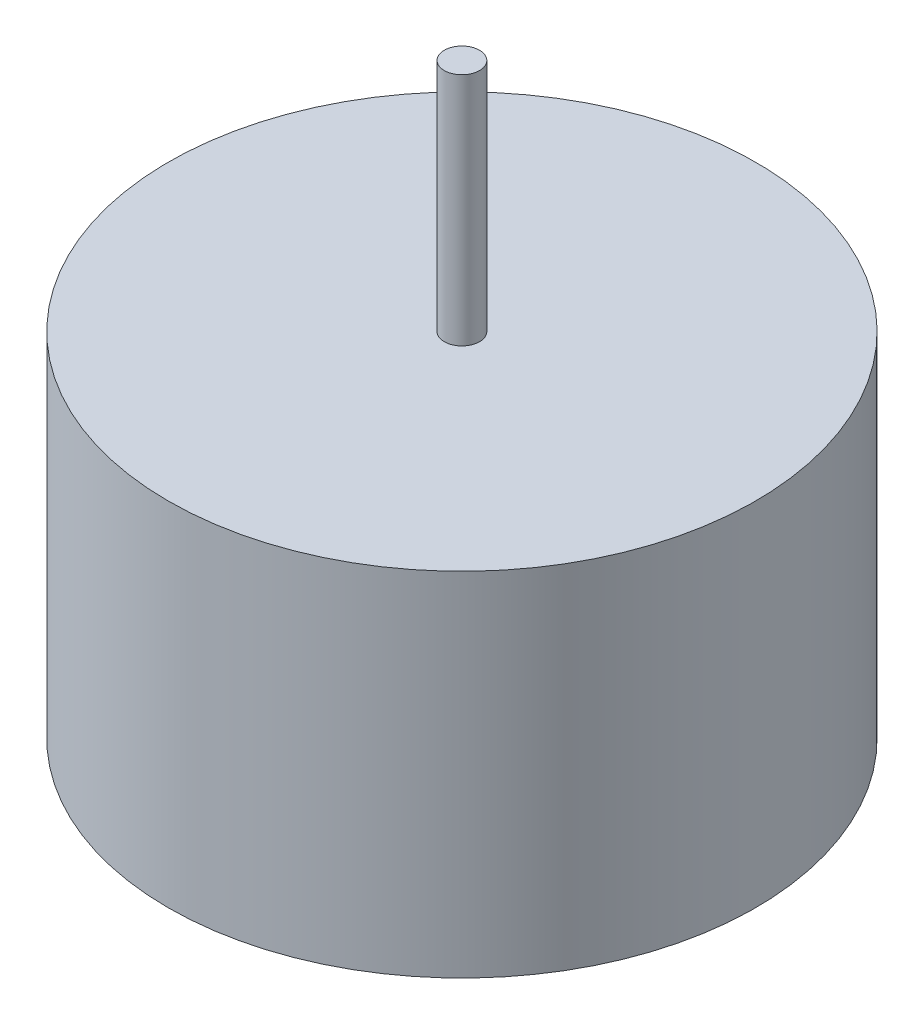
from build123d import *

# Parameters (mm, degrees)
SKETCH1_R           = 25
BOSS_EXTRUDE1_DEPTH = 30
SKETCH2_R           = 1.5
BOSS_EXTRUDE2_DEPTH = 20


with BuildPart() as part:
    # Sketch1 → Boss-Extrude1 (new body)
    with BuildSketch(Plane(origin=(0, 0, 0), x_dir=(1, 0, 0), z_dir=(0, 1, 0))):
        Circle(SKETCH1_R)
    extrude(amount=BOSS_EXTRUDE1_DEPTH)

    # Sketch2 → Boss-Extrude2 (add)
    with BuildSketch(Plane(origin=(0, 30, 0), x_dir=(1, 0, 0), z_dir=(0, 1, 0))):
        Circle(SKETCH2_R)
    extrude(amount=BOSS_EXTRUDE2_DEPTH)


solid = part.part
